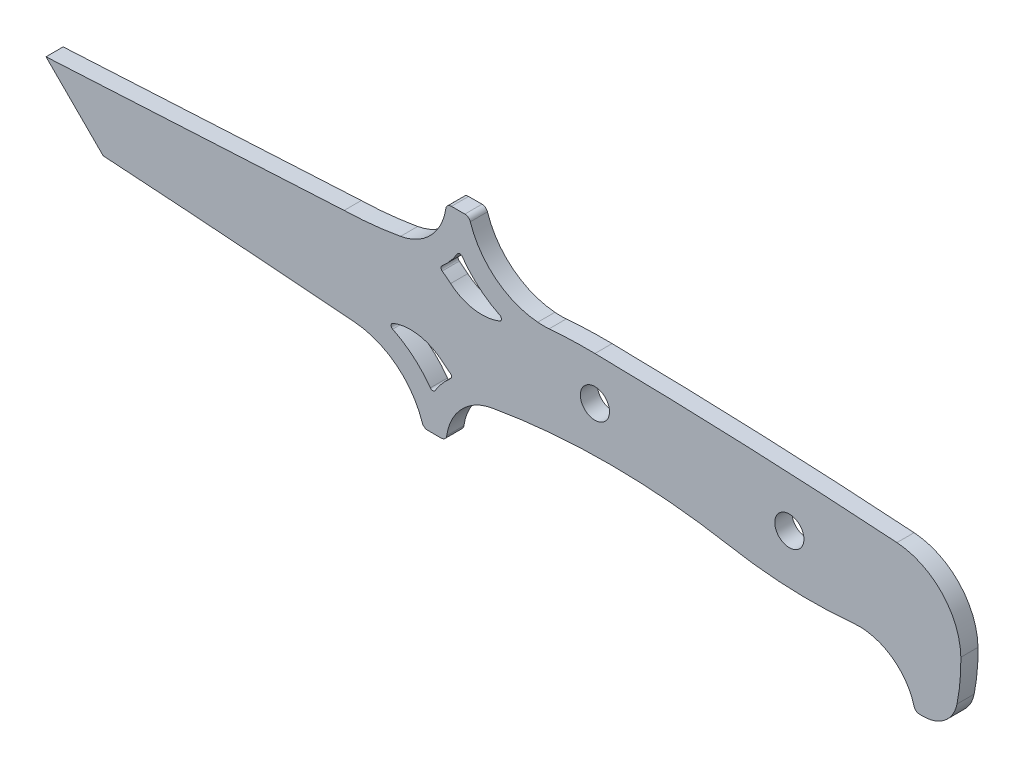
from build123d import *

# Parameters (mm, degrees)
EXTRUDE_1_DEPTH          = 1.5
CUT_EXTRUDE_1_DEPTH      = 93.954236052
CUT_EXTRUDE_1_DEPTH_BACK = 93.954236052
FILLET_2_R               = 0.5
CUT_EXTRUDE_2_DEPTH      = 93.954236175
CUT_EXTRUDE_2_DEPTH_BACK = 93.954236175
SKETCH_1_3_R             = 2.55
FILLET_3_R               = 1
FILLET_4_R               = 6


with BuildPart() as part:
    # 草图3 → 凸台-拉伸1 (new, symmetric)
    with BuildSketch(Plane.XY):
        with BuildLine():
            Line((-69, 0.053699407), (-17.857896917, 2.8))
            ThreePointArc((-17.857896917, 2.8), (-12.910589699, 3.119021237), (-8, 3.8))
            ThreePointArc((-8, 3.8), (-2.43432215, 6.908286356), (0, 12.8))
            Line((0, 12.8), (4, 12.8))
            ThreePointArc((4, 12.8), (8.414270073, 5.897124087), (16, 2.8))
            ThreePointArc((16, 2.8), (17, 2.759720994), (18, 2.8))
            ThreePointArc((18, 2.8), (21.996883494, 3.025702827), (26, 3.058530741))
            ThreePointArc((26, 3.058530741), (52.423511602, 2.290913304), (78.817734107, 0.82933187))
            ThreePointArc((78.817734107, 0.82933187), (86.700158242, -2.881010306), (89.995283198, -10.945835216))
            ThreePointArc((89.995283198, -10.945835216), (89.543787999, -17.161843843), (88, -23.2))
            Line((88, -23.2), (82, -23.2))
            ThreePointArc((82, -23.2), (78.162031949, -17.126267779), (71.242138758, -15.193575339))
            ThreePointArc((71.242138758, -15.193575339), (60.309670553, -15.485417284), (49.439553231, -14.283509554))
            ThreePointArc((49.439553231, -14.283509554), (28.723471343, -12.408337394), (8, -14.2))
            ThreePointArc((8, -14.2), (2.43432215, -17.308286356), (0, -23.2))
            Line((0, -23.2), (-4, -23.2))
            ThreePointArc((-4, -23.2), (-8.414270073, -16.297124087), (-16, -13.2))
            ThreePointArc((-16, -13.2), (-37.993667939, -11.512934158), (-60, -10))
            Line((-60, -10), (-70, 0))
            Line((-70, 0), (-69, 0.053699407))
        make_face()
    extrude(amount=EXTRUDE_1_DEPTH, both=True)

    # 草图1 → 切除-拉伸1 (cut, two sides: drawn at the far end of the back side and taken through both)
    with BuildSketch(Plane.XY.offset(-CUT_EXTRUDE_1_DEPTH_BACK)):
        with BuildLine():
            ThreePointArc((-0.762235002, -11.434746091), (-5.407803908, -9.481675026), (-10.342236489, -10.504989325))
            ThreePointArc((-10.342236489, -10.504989325), (-5.834327754, -13.240266104), (-2.342236489, -17.190997533))
            ThreePointArc((-2.342236489, -17.190997533), (-0.767930164, -14.895803013), (1.237764998, -12.966154029))
            ThreePointArc((1.237764998, -12.966154029), (0.220251061, -12.223323048), (-0.762235002, -11.434746091))
        make_face()
        with BuildLine():
            ThreePointArc((-1.237764998, 2.566154029), (-0.220251061, 1.823323048), (0.762235002, 1.034746091))
            ThreePointArc((0.762235002, 1.034746091), (5.407803908, -0.918324974), (10.342236489, 0.104989325))
            ThreePointArc((10.342236489, 0.104989325), (5.834327754, 2.840266104), (2.342236489, 6.790997533))
            ThreePointArc((2.342236489, 6.790997533), (0.767930164, 4.495803013), (-1.237764998, 2.566154029))
        make_face()
    extrude(amount=CUT_EXTRUDE_1_DEPTH + CUT_EXTRUDE_1_DEPTH_BACK, mode=Mode.SUBTRACT)

    # 圆角2
    fillet_2_edges = [part.edges().sort_by_distance(p)[0] for p in [
        (-10.342236489, -10.504989325, 0),
        (-2.342236489, -17.190997533, 0),
        (1.237764998, -12.966154029, 0),
        (10.342236489, 0.104989325, 0),
        (2.342236489, 6.790997533, 0),
        (-1.237764998, 2.566154029, 0),
    ]]
    fillet(fillet_2_edges, radius=FILLET_2_R)

    # 草图1<3> → 切除-拉伸2 (cut, two sides: drawn at the far end of the back side and taken through both)
    with BuildSketch(Plane.XY.offset(-CUT_EXTRUDE_2_DEPTH_BACK)):
        with Locations((60, -6.8)):
            Circle(SKETCH_1_3_R)
        with Locations((26, -4.5)):
            Circle(SKETCH_1_3_R)
    extrude(amount=CUT_EXTRUDE_2_DEPTH + CUT_EXTRUDE_2_DEPTH_BACK, mode=Mode.SUBTRACT)

    # 圆角3
    fillet_3_edges = [part.edges().sort_by_distance(p)[0] for p in [
        (0, -23.2, 0),
        (-4, -23.2, 0),
        (4, 12.8, 0),
        (0, 12.8, 0),
        (82, -23.2, 0),
    ]]
    fillet(fillet_3_edges, radius=FILLET_3_R)

    # 圆角4
    fillet_4_edges = [part.edges().sort_by_distance(p)[0] for p in [
        (88, -23.2, 0),
    ]]
    fillet(fillet_4_edges, radius=FILLET_4_R)


solid = part.part
